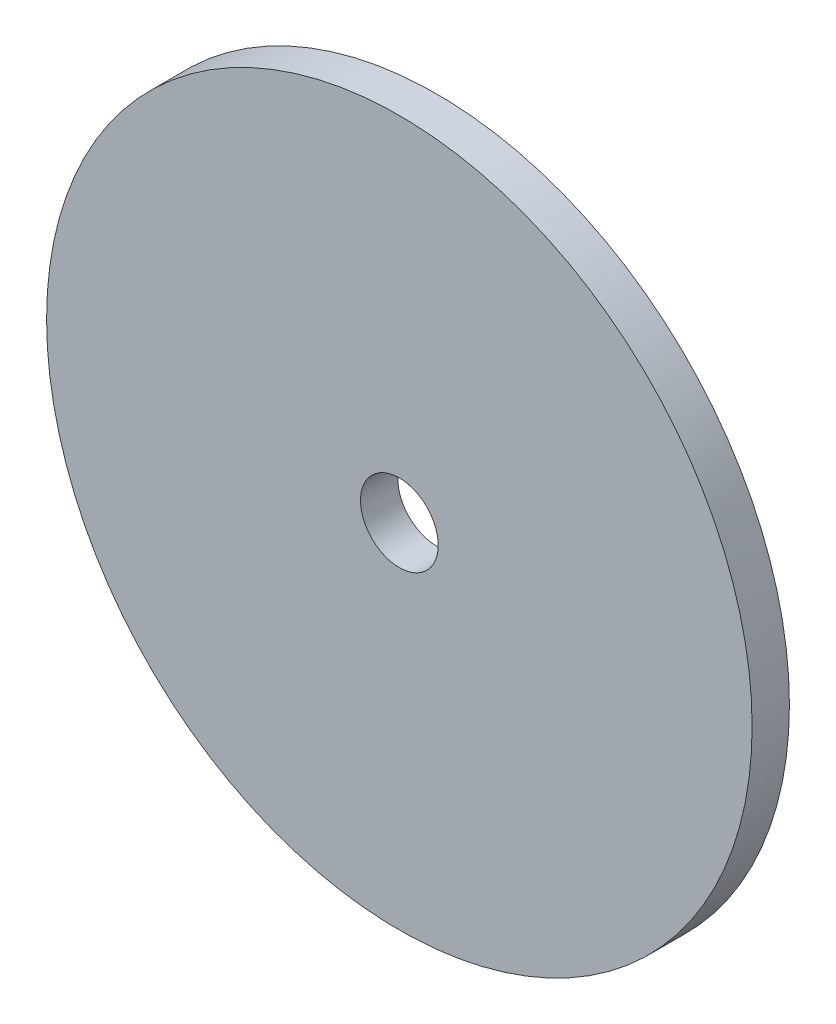
from build123d import *

# Parameters (mm, degrees)
SKETCH1_R           = 28.829
BOSS_EXTRUDE1_DEPTH = 3.048
SKETCH2_R           = 3.175
CUT_EXTRUDE1_DEPTH  = 3.048


with BuildPart() as part:
    # Sketch1 → Boss-Extrude1 (new body)
    with BuildSketch(Plane.XY):
        Circle(SKETCH1_R)
    extrude(amount=BOSS_EXTRUDE1_DEPTH)

    # Sketch2 → Cut-Extrude1 (cut)
    with BuildSketch(Plane.XY.offset(3.048)):
        Circle(SKETCH2_R)
    extrude(amount=-CUT_EXTRUDE1_DEPTH, mode=Mode.SUBTRACT)


solid = part.part
